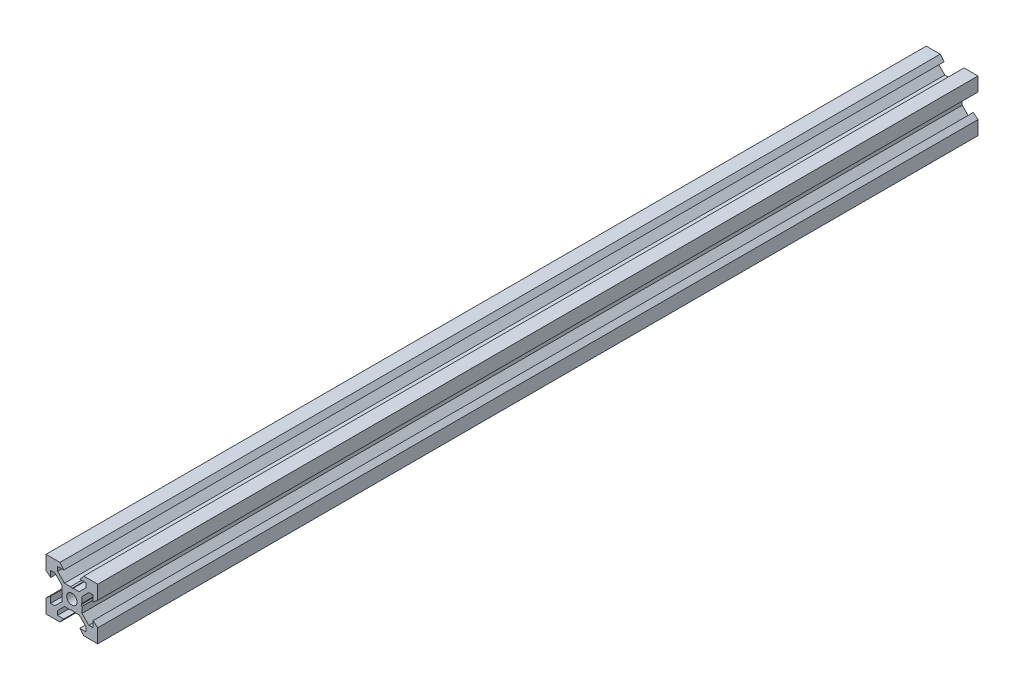
from build123d import *

# Parameters (mm, degrees)
SKETCH1_R           = 2
BOSS_EXTRUDE1_DEPTH = 170.165


with BuildPart() as part:
    # Sketch1 → Boss-Extrude1 (new body, symmetric)
    with BuildSketch(Plane.XY):
        Polygon((10, 10), (10, 4.610379336), (8.2, 3.1), (8.2, 5.5), (6.560660172, 5.5), (3.9, 2.839339828), (3.9, 0.519615242), (3.6, 0), (3.9, -0.519615242), (3.9, -2.839339828), (6.560660172, -5.5), (8.2, -5.5), (8.2, -3.1), (10, -4.610379336), (10, -10), (4.610379336, -10), (3.1, -8.2), (5.5, -8.2), (5.5, -6.560660172), (2.839339828, -3.9), (0.519615242, -3.9), (0, -3.6), (-0.519615242, -3.9), (-2.839339828, -3.9), (-5.5, -6.560660172), (-5.5, -8.2), (-3.1, -8.2), (-4.610379336, -10), (-10, -10), (-10, -4.610379336), (-8.2, -3.1), (-8.2, -5.5), (-6.560660172, -5.5), (-3.9, -2.839339828), (-3.9, -0.519615242), (-3.6, 0), (-3.9, 0.519615242), (-3.9, 2.839339828), (-6.560660172, 5.5), (-8.2, 5.5), (-8.2, 3.1), (-10, 4.610379336), (-10, 10), (-4.610379336, 10), (-3.1, 8.2), (-5.5, 8.2), (-5.5, 6.560660172), (-2.839339828, 3.9), (-0.519615242, 3.9), (0, 3.6), (0.519615242, 3.9), (2.839339828, 3.9), (5.5, 6.560660172), (5.5, 8.2), (3.1, 8.2), (4.610379336, 10), align=None)
        Circle(SKETCH1_R, mode=Mode.SUBTRACT)
    extrude(amount=BOSS_EXTRUDE1_DEPTH, both=True)


solid = part.part
